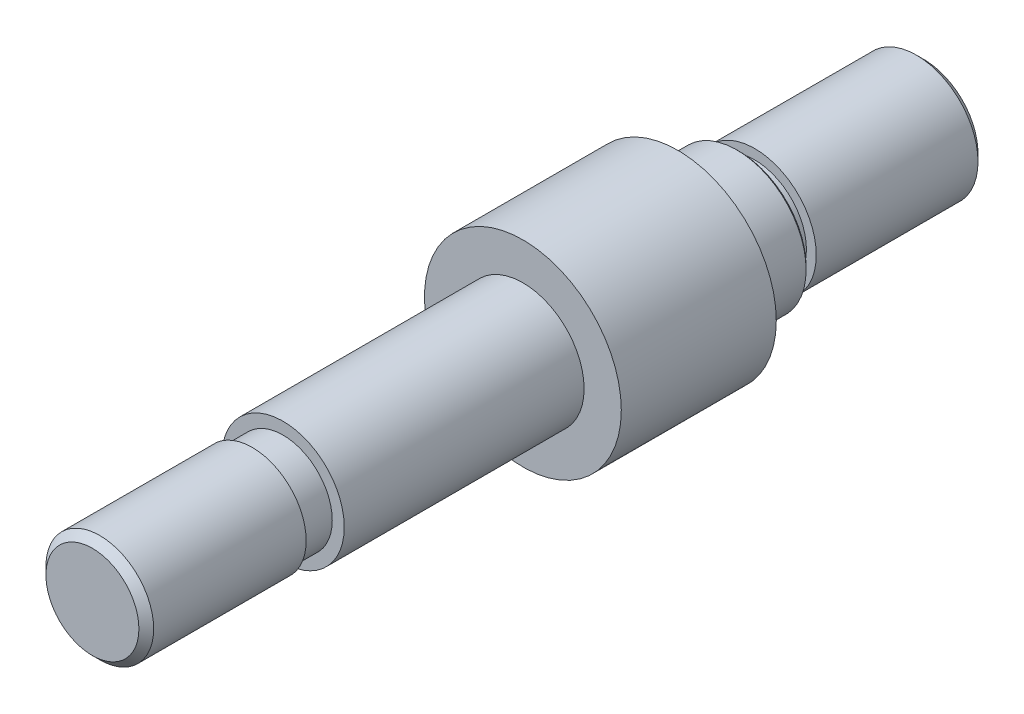
from build123d import *

# Parameters (mm, degrees)
SKETCH1_R           = 7.14375
BOSS_EXTRUDE1_DEPTH = 6.35
SKETCH2_R           = 10.16
BOSS_EXTRUDE2_DEPTH = 16.002
CHAMFER1_SIZE       = 0.254
SKETCH3_R           = 6.31825
BOSS_EXTRUDE3_DEPTH = 44.45
SKETCH5_R           = 6.35
BOSS_EXTRUDE4_DEPTH = 19.05
SKETCH11_R          = 6.31825
SKETCH11_R_2        = 5.5626
CUT_EXTRUDE2_DEPTH  = 16.51
CHAMFER2_SIZE       = 0.762
SKETCH8_W           = 1.016
SKETCH8_H           = 1.5875
SKETCH10_W          = 1.27
SKETCH10_H          = 3.175


with BuildPart() as part:
    # Sketch1 → Boss-Extrude1 (new body)
    with BuildSketch(Plane.XY):
        Circle(SKETCH1_R)
    extrude(amount=-BOSS_EXTRUDE1_DEPTH)

    # Sketch2 → Boss-Extrude2 (add)
    with BuildSketch(Plane.XY):
        Circle(SKETCH2_R)
    extrude(amount=BOSS_EXTRUDE2_DEPTH)

    # Chamfer1
    chamfer1_edges = [part.edges().sort_by_distance(p)[0] for p in [
        (-7.14375, 0, -6.35),
    ]]
    chamfer(chamfer1_edges, length=CHAMFER1_SIZE)

    # Sketch3 → Boss-Extrude3 (add)
    with BuildSketch(Plane.XY.offset(16.002)):
        Circle(SKETCH3_R)
    extrude(amount=BOSS_EXTRUDE3_DEPTH)

    # Sketch5 → Boss-Extrude4 (add)
    with BuildSketch(Plane(origin=(0, 0, -6.35), x_dir=(-1, 0, 0), z_dir=(0, 0, -1))):
        Circle(SKETCH5_R)
    extrude(amount=BOSS_EXTRUDE4_DEPTH)

    # Sketch11 → Cut-Extrude2 (cut)
    with BuildSketch(Plane.XY.offset(60.452)):
        Circle(SKETCH11_R)
        Circle(SKETCH11_R_2, mode=Mode.SUBTRACT)
    extrude(amount=-CUT_EXTRUDE2_DEPTH, mode=Mode.SUBTRACT)

    # Chamfer2
    chamfer2_edges = [part.edges().sort_by_distance(p)[0] for p in [
        (6.35, 0, -25.4),
        (-5.5626, 0, 60.452),
    ]]
    chamfer(chamfer2_edges, length=CHAMFER2_SIZE)

    # Sketch8 → Cut-Revolve3 (revolve, cut)
    with BuildSketch(Plane(origin=(0, 0, 0), x_dir=(1, 0, 0), z_dir=(0, 1, 0))):
        with Locations((-5.842, 7.14375)):
            Rectangle(SKETCH8_W, SKETCH8_H)
    revolve(axis=Axis((0, 0, 0), (0, 0, -1)), mode=Mode.SUBTRACT)

    # Sketch10 → Cut-Revolve4 (revolve, cut)
    with BuildSketch(Plane(origin=(0, 0, 0), x_dir=(1, 0, 0), z_dir=(0, 1, 0))):
        with Locations((-5.715, -42.3545)):
            Rectangle(SKETCH10_W, SKETCH10_H)
    revolve(axis=Axis((0, 0, 67.984878541), (0, 0, -1)), mode=Mode.SUBTRACT)


solid = part.part
